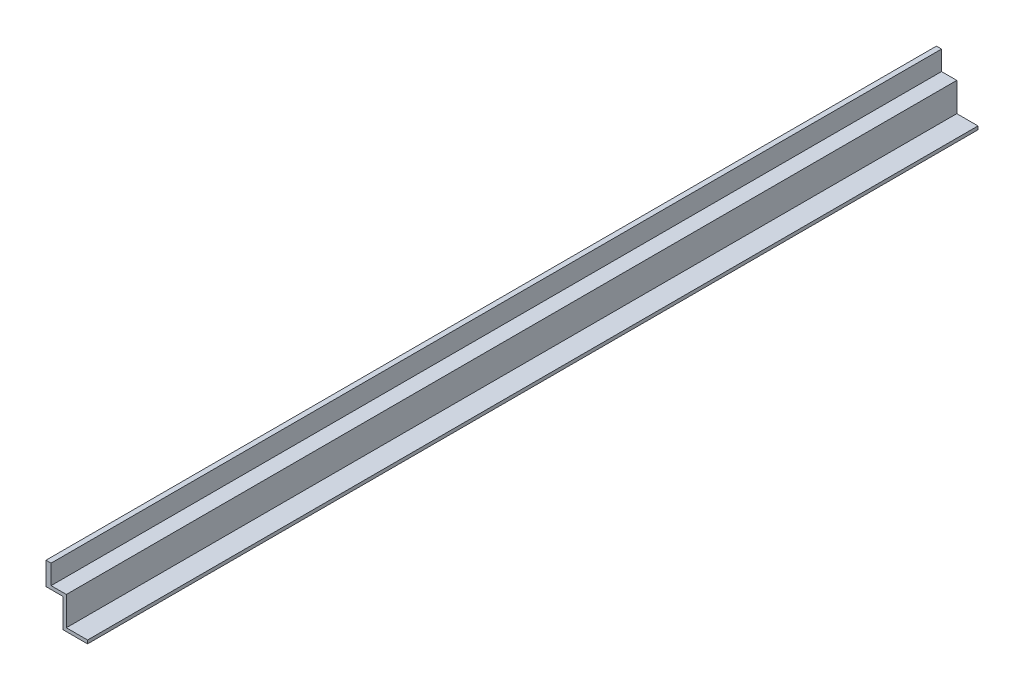
from build123d import *

# Parameters (mm, degrees)
CROQUIS1_W              = 6
CROQUIS1_H              = 1050
SALIENTE_EXTRUIR1_DEPTH = 23
CROQUIS2_W              = 24
CROQUIS2_H              = 4
SALIENTE_EXTRUIR2_DEPTH = 1050
CROQUIS3_W              = 4
CROQUIS3_H              = 30
SALIENTE_EXTRUIR3_DEPTH = 1050
CROQUIS4_W              = 29
CROQUIS4_H              = 4
SALIENTE_EXTRUIR4_DEPTH = 1050


with BuildPart() as part:
    # Croquis1 → Saliente-Extruir1 (new body)
    with BuildSketch(Plane(origin=(0, 0, 0), x_dir=(1, 0, 0), z_dir=(0, 1, 0))):
        with Locations((3, -525)):
            Rectangle(CROQUIS1_W, CROQUIS1_H)
    extrude(amount=-SALIENTE_EXTRUIR1_DEPTH)

    # Croquis2 → Saliente-Extruir2 (add)
    with BuildSketch(Plane.XY.offset(1050)):
        with Locations((12, -25)):
            Rectangle(CROQUIS2_W, CROQUIS2_H)
    extrude(amount=-SALIENTE_EXTRUIR2_DEPTH)

    # Croquis3 → Saliente-Extruir3 (add)
    with BuildSketch(Plane.XY.offset(1050)):
        with Locations((22, -42)):
            Rectangle(CROQUIS3_W, CROQUIS3_H)
    extrude(amount=-SALIENTE_EXTRUIR3_DEPTH)

    # Croquis4 → Saliente-Extruir4 (add)
    with BuildSketch(Plane.XY.offset(1050)):
        with Locations((34.5, -59)):
            Rectangle(CROQUIS4_W, CROQUIS4_H)
    extrude(amount=-SALIENTE_EXTRUIR4_DEPTH)


solid = part.part
